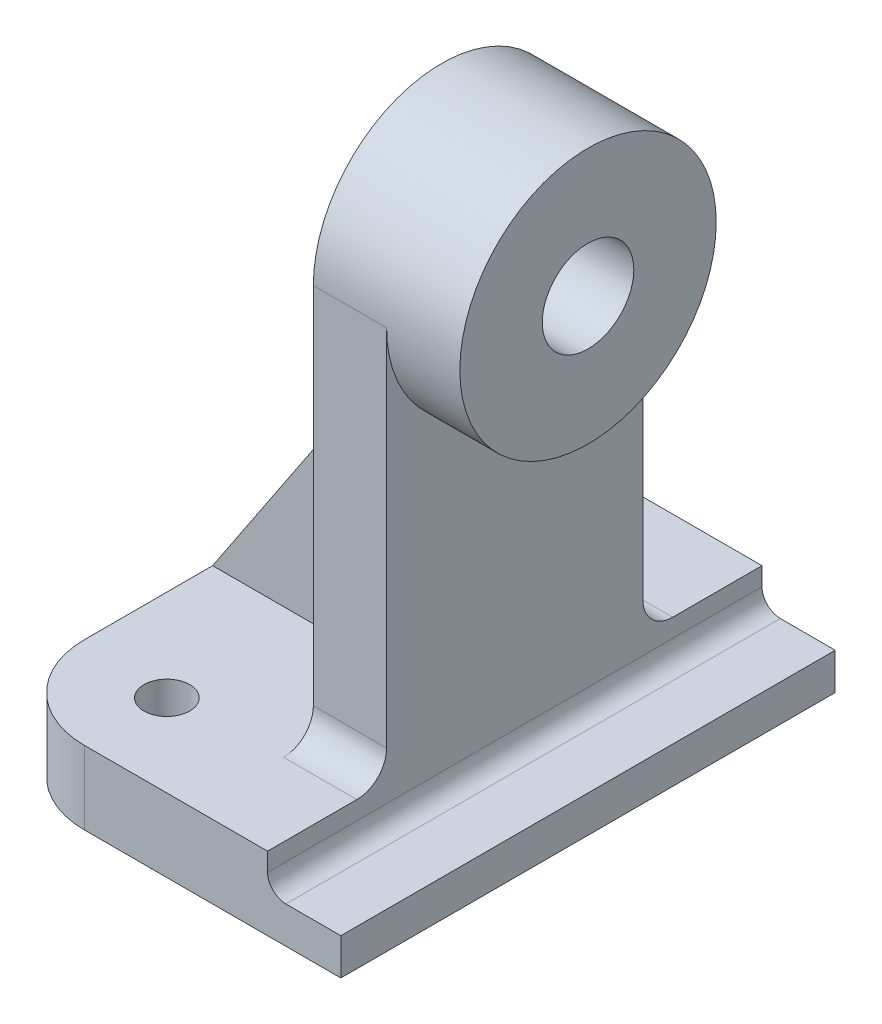
from build123d import *

# Parameters (mm, degrees)
Y_KSEKLIK_EKSTR_ZYON2_DEPTH      = 8
IZIM4_R                          = 2.5
KES_EKSTR_ZYON1_DEPTH            = 8
KES_EKSTR_ZYON2_DEPTH            = 54
IZIM13_W                         = 8
IZIM13_H                         = 41
Y_KSEKLIK_EKSTR_ZYON8_DEPTH      = 43
KES_EKSTR_ZYON7_DEPTH            = 43
IZIM15_R                         = 14
Y_KSEKLIK_EKSTR_ZYON9_DEPTH      = 8
Y_KSEKLIK_EKSTR_ZYON9_DEPTH_BACK = 8
IZIM16_R                         = 5
KES_EKSTR_ZYON8_DEPTH            = 16
FEDER12_REACH                    = 74.904
IZIM17_WALL_W                    = 187.469157084
IZIM17_WALL_H                    = 6


with BuildPart() as part:
    # Çizim3 → Yükseklik-Ekstrüzyon2 (new body)
    with BuildSketch(Plane(origin=(0, 0, 0), x_dir=(1, 0, 0), z_dir=(0, 1, 0))):
        with BuildLine():
            Line((-19, -17), (-19, 17))
            ThreePointArc((-19, 17), (-16.071067812, 24.071067812), (-9, 27))
            Line((-9, 27), (19, 27))
            Line((19, 27), (19, -27))
            Line((19, -27), (-9, -27))
            ThreePointArc((-9, -27), (-16.071067812, -24.071067812), (-19, -17))
        make_face()
    extrude(amount=Y_KSEKLIK_EKSTR_ZYON2_DEPTH)

    # Çizim4 → Kes-Ekstrüzyon1 (cut)
    with BuildSketch(Plane(origin=(0, 8, 0), x_dir=(1, 0, 0), z_dir=(0, 1, 0))):
        with Locations(Location((-9, -18, 0), (0, 0, 270))):
            Circle(IZIM4_R)
        with Locations(Location((-9, 18, 0), (0, 0, 90))):
            Circle(IZIM4_R)
    extrude(amount=-KES_EKSTR_ZYON1_DEPTH, mode=Mode.SUBTRACT)

    # Çizim5 → Kes-Ekstrüzyon2 (cut)
    with BuildSketch(Plane.XY.offset(27)):
        with BuildLine():
            Line((11, 8), (19, 8))
            Line((19, 8), (19, 4))
            Line((19, 4), (13, 4))
            ThreePointArc((13, 4), (11.585786438, 4.585786438), (11, 6))
            Line((11, 6), (11, 8))
        make_face()
    extrude(amount=-KES_EKSTR_ZYON2_DEPTH, mode=Mode.SUBTRACT)

    # Çizim13 → Yükseklik-Ekstrüzyon8 (add)
    with BuildSketch(Plane(origin=(0, 8, 0), x_dir=(1, 0, 0), z_dir=(0, 1, 0))):
        with Locations((7, 0)):
            Rectangle(IZIM13_W, IZIM13_H)
    extrude(amount=Y_KSEKLIK_EKSTR_ZYON8_DEPTH)

    # Çizim14 → Kes-Ekstrüzyon7 (cut)
    with BuildSketch(Plane.ZY.offset(-3)):
        with BuildLine():
            Line((20.5, 8), (20.5, 51))
            Line((20.5, 51), (14, 51))
            Line((14, 51), (14, 11.25))
            ThreePointArc((14, 11.25), (14.951902961, 8.951902961), (17.25, 8))
            Line((17.25, 8), (20.5, 8))
        make_face()
        with BuildLine():
            Line((-20.5, 51), (-14, 51))
            Line((-14, 51), (-14, 11.25))
            ThreePointArc((-14, 11.25), (-14.951902961, 8.951902961), (-17.25, 8))
            Line((-17.25, 8), (-20.5, 8))
            Line((-20.5, 8), (-20.5, 51))
        make_face()
    extrude(amount=-KES_EKSTR_ZYON7_DEPTH, mode=Mode.SUBTRACT)

    # Çizim15 → Yükseklik-Ekstrüzyon9 (add, two sides)
    with BuildSketch(Plane(origin=(11, 0, 0), x_dir=(0, 0, -1), z_dir=(1, 0, 0))) as y_kseklik_ekstr_zyon9_sk:
        with Locations((0, 51)):
            Circle(IZIM15_R)
    extrude(amount=Y_KSEKLIK_EKSTR_ZYON9_DEPTH)
    extrude(y_kseklik_ekstr_zyon9_sk.sketch, amount=-Y_KSEKLIK_EKSTR_ZYON9_DEPTH_BACK)

    # Çizim16 → Kes-Ekstrüzyon8 (cut)
    with BuildSketch(Plane(origin=(19, 0, 0), x_dir=(0, 0, -1), z_dir=(1, 0, 0))):
        with Locations((0, 51)):
            Circle(IZIM16_R)
    extrude(amount=-KES_EKSTR_ZYON8_DEPTH, mode=Mode.SUBTRACT)

    # Çizim17 wall → Feder12 (add, up to next)
    with BuildSketch(Plane(origin=(-8, 24.5, 0), x_dir=(0.554700196225, 0.832050294338, 0), z_dir=(-0.832050294338, 0.554700196225, 0)), mode=Mode.PRIVATE) as feder12_sk1:
        Rectangle(IZIM17_WALL_W, IZIM17_WALL_H)
    feder12_tool1 = extrude(feder12_sk1.sketch, amount=-FEDER12_REACH, mode=Mode.PRIVATE) - part.part
    add(feder12_tool1.solids().sort_by_distance((-8, 24.5, 0))[0])


solid = part.part
